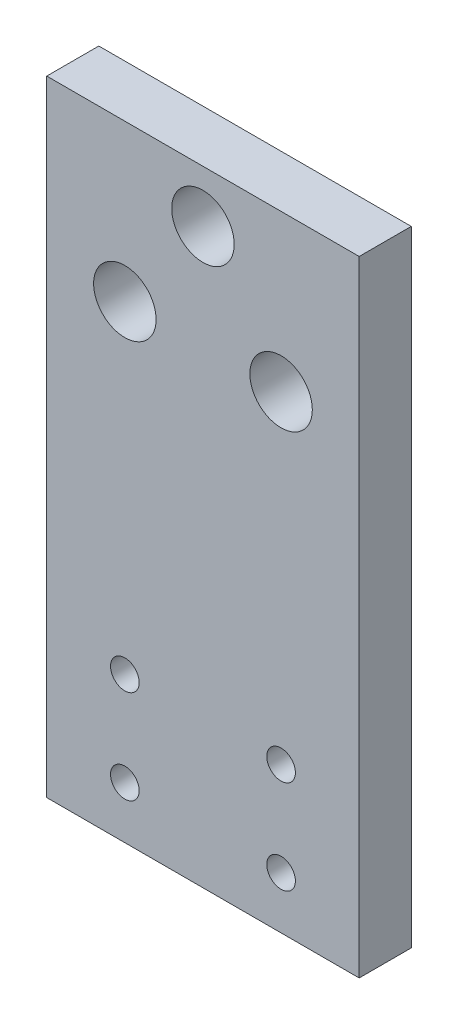
from build123d import *

# Parameters (mm, degrees)
SKETCH_1_W      = 60
SKETCH_1_H      = 120
EXTRUDE_1_DEPTH = 10
MM_1_D          = 5.5
MM_1_DEPTH      = 15
MM_1_TIP        = 1.652366702
MM_1_2_D        = 12
MM_1_2_DEPTH    = 15
MM_1_2_TIP      = 3.605163714


with BuildPart() as part:
    # 草图1 → 凸台-拉伸1 (new body)
    with BuildSketch(Plane.XY):
        Rectangle(SKETCH_1_W, SKETCH_1_H)
    extrude(amount=EXTRUDE_1_DEPTH)

    # mm _1
    with Locations(Plane(origin=(-15, -32, 10), x_dir=(1, 0, 0), z_dir=(0, 0, 1))):
        with Locations((0, 0), (30, 0), (30, -18), (0, -18)):
            Hole(MM_1_D / 2, depth=MM_1_DEPTH)
            with Locations((0, 0, -(MM_1_DEPTH + MM_1_TIP / 2))):  # 118° drill point
                Cone(0, MM_1_D / 2, MM_1_TIP, mode=Mode.SUBTRACT)

    # mm _1 2
    with Locations(Plane.XY.offset(10)):
        with Locations((-15, 30), (15, 30), (0, 50)):
            Hole(MM_1_2_D / 2, depth=MM_1_2_DEPTH)
            with Locations((0, 0, -(MM_1_2_DEPTH + MM_1_2_TIP / 2))):  # 118° drill point
                Cone(0, MM_1_2_D / 2, MM_1_2_TIP, mode=Mode.SUBTRACT)


solid = part.part
